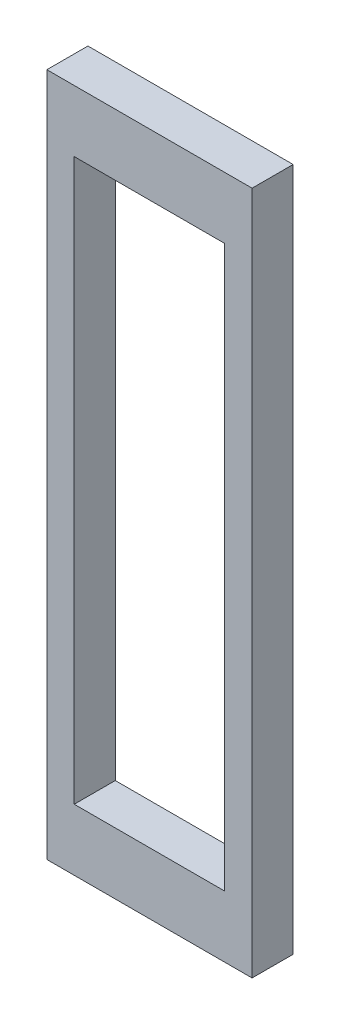
from build123d import *

# Parameters (mm, degrees)
SKETCH_3_W      = 15
SKETCH_3_H      = 50
SKETCH_3_W_2    = 11
SKETCH_3_H_2    = 41
EXTRUDE_1_DEPTH = 3


with BuildPart() as part:
    # 스케치3 → 보스-돌출1 (new body)
    with BuildSketch(Plane(origin=(0, 0, 0), x_dir=(-1, 0, 0), z_dir=(0, 0, -1))):
        Rectangle(SKETCH_3_W, SKETCH_3_H)
        Rectangle(SKETCH_3_W_2, SKETCH_3_H_2, mode=Mode.SUBTRACT)
    extrude(amount=EXTRUDE_1_DEPTH)


solid = part.part
